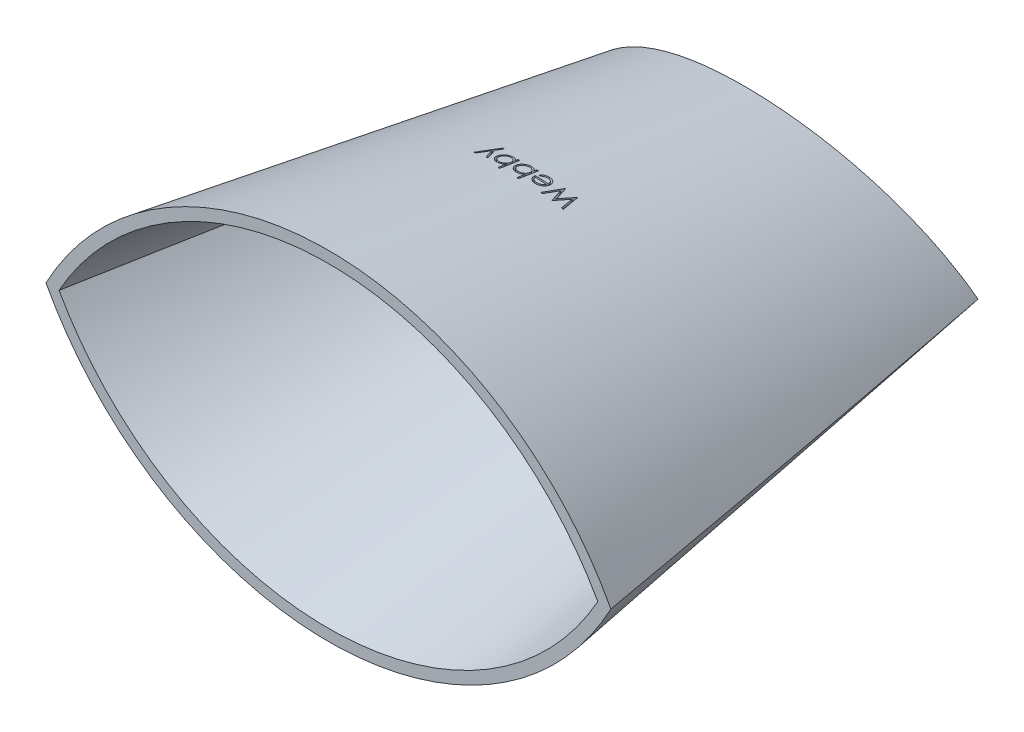
from build123d import *

# Parameters (mm, degrees)
EXTRUDE_2_DEPTH     = 80
EXTRUDE_2_DRAFT     = -9
CUT_EXTRUDE_3_DEPTH = 40
SHELL_4_T           = -2
CUT_EXTRUDE_4_DEPTH = 1


with BuildPart() as part:
    # 草圖13 → 填料-伸長2 (with draft: the straight prism first)
    with BuildSketch(Plane.XY):
        with BuildLine():
            ThreePointArc((-50, 0), (0, -30), (50, 0))
            ThreePointArc((50, 0), (0, 30), (-50, 0))
        make_face()
    extrude(amount=-EXTRUDE_2_DEPTH)
    # 填料-伸長2: the draft: its side faces are tilted about the plane it starts from
    extrude_2_sides = [part.faces().sort_by_distance(p)[0] for p in [
        (0, -30, -40),
        (0, 30, -40),
    ]]
    draft(extrude_2_sides, Plane.XY, EXTRUDE_2_DRAFT)

    # 草圖24 → 除料-伸長3 (cut, symmetric)
    with BuildSketch(Plane(origin=(0, 0, 0), x_dir=(1, 0, 0), z_dir=(0, 1, 0))):
        with BuildLine():
            Line((-34.993272388, 80), (34.993272388, 80))
            ThreePointArc((34.993272388, 80), (0, 73.64656094), (-34.993272388, 80))
        make_face()
    extrude(amount=CUT_EXTRUDE_3_DEPTH, both=True, mode=Mode.SUBTRACT)

    # 薄殼4
    shell_4_openings = [part.faces().sort_by_distance(p)[0] for p in [
        (0, 0, 0),
    ]]
    offset(amount=SHELL_4_T, openings=shell_4_openings)

    # 草圖30 → 除料-伸長4 (cut)
    with BuildSketch(Plane(origin=(0, 29.265847744, -4.635254916), x_dir=(0, -0.156434465, -0.987688341), z_dir=(0, -0.987688341, 0.156434465))):
        Polygon((28.840498656, 8.566973044), (28.840498656, 8.242353653), (31.407305547, 7.55735766), (28.840498656, 6.538627692), (28.840498656, 6.493054775), (31.389777502, 5.493255095), (28.840498656, 4.804753493), (28.840498656, 4.483639711), (32.340498656, 5.427349647), (32.340498656, 5.472221442), (29.663615643, 6.525306377), (32.340498656, 7.591011506), (32.340498656, 7.635883301), align=None)
        with BuildLine():
            Line((31.532806348, 1.666532339), (31.679340803, 1.387485865))
            add(Edge.make_bspline(
                [(31.679340803, 1.387485865), (31.718774784, 1.409734126), (31.795497696, 1.453020431), (31.900911664, 1.527157354), (31.995179199, 1.605585821), (32.076790805, 1.690692099), (32.148863988, 1.779911575), (32.211031138, 1.874938806), (32.264413976, 1.974998142), (32.30815623, 2.081191686), (32.342544509, 2.193392229), (32.367940487, 2.312250839), (32.382667742, 2.438328721), (32.384455188, 2.524666683), (32.385370451, 2.568876089)],
                knots=[0, 0, 0, 0, 0.000135759, 0.000264133, 0.000386042, 0.00050306, 0.000617265, 0.000729664, 0.000843204, 0.000957002, 0.001073654, 0.001194802, 0.001321164, 0.001453767, 0.001453767, 0.001453767, 0.001453767], degree=3))
            add(Edge.make_bspline(
                [(32.385370451, 2.568876089), (32.384223275, 2.618018066), (32.381985468, 2.713879828), (32.362693004, 2.853419576), (32.331220644, 2.984798991), (32.287255108, 3.108010708), (32.229827763, 3.222752908), (32.15986836, 3.329253959), (32.077735806, 3.428072743), (31.982720501, 3.516099768), (31.881034318, 3.595333204), (31.775093709, 3.665296784), (31.665265558, 3.723516513), (31.55220332, 3.771598492), (31.436163915, 3.809526063), (31.316482774, 3.836477979), (31.193634466, 3.851871128), (31.110538858, 3.854240542), (31.06866372, 3.855434583)],
                knots=[0, 0, 0, 0, 0.000147371, 0.000287478, 0.000421649, 0.000552053, 0.000679042, 0.000805636, 0.000933558, 0.00106351, 0.001193382, 0.001319977, 0.001443869, 0.00156576, 0.001688149, 0.001809597, 0.001933259, 0.002058885, 0.002058885, 0.002058885, 0.002058885], degree=3))
            add(Edge.make_bspline(
                [(31.06866372, 3.855434583), (31.029368889, 3.854375441), (30.951491725, 3.852276363), (30.83622618, 3.839045576), (30.724197728, 3.815597283), (30.61531328, 3.783420959), (30.509755146, 3.741869712), (30.407459082, 3.691037493), (30.308533942, 3.630845115), (30.246130808, 3.584372442), (30.214697374, 3.560963429)],
                knots=[0, 0, 0, 0, 0.000117891, 0.000233644, 0.000347498, 0.000460856, 0.000573868, 0.000687374, 0.000803169, 0.000920699, 0.000920699, 0.000920699, 0.000920699], degree=3))
            add(Edge.make_bspline(
                [(30.214697374, 3.560963429), (30.176765715, 3.52931041), (30.102225818, 3.467108733), (30.005175994, 3.360811972), (29.922158166, 3.247262192), (29.854432058, 3.125317218), (29.802339973, 2.995182459), (29.765287562, 2.857529141), (29.742231859, 2.711976793), (29.739388767, 2.612199066), (29.737934553, 2.561163749)],
                knots=[0, 0, 0, 0, 0.000148071, 0.000290976, 0.000430515, 0.000569233, 0.000708282, 0.00084996, 0.000996123, 0.001149162, 0.001149162, 0.001149162, 0.001149162], degree=3))
            add(Edge.make_bspline(
                [(29.737934553, 2.561163749), (29.73928182, 2.508713128), (29.741924852, 2.405816966), (29.766647003, 2.255827455), (29.805375739, 2.113625549), (29.861801668, 1.980384767), (29.931745462, 1.854052066), (30.020151142, 1.737534978), (30.122478089, 1.627635033), (30.201253895, 1.563733148), (30.241340002, 1.531215833)],
                knots=[0, 0, 0, 0, 0.000157241, 0.00030847, 0.000454763, 0.000598385, 0.000741531, 0.000886803, 0.001036096, 0.001190777, 0.001190777, 0.001190777, 0.001190777], degree=3))
            add(Edge.make_bspline(
                [(30.241340002, 1.531215833), (30.271543583, 1.509088894), (30.331749702, 1.464982301), (30.429920859, 1.409735201), (30.532631453, 1.361777806), (30.64154175, 1.323444845), (30.755361331, 1.292405344), (30.874903875, 1.269948525), (31.000133787, 1.256778907), (31.085460342, 1.254190209), (31.128960194, 1.25287048)],
                knots=[0, 0, 0, 0, 0.000112234, 0.000223721, 0.000337279, 0.000451932, 0.000569628, 0.000690912, 0.000816421, 0.00094695, 0.00094695, 0.00094695, 0.00094695], degree=3))
            Line((31.128960194, 1.25287048), (31.128960194, 3.541332019))
            add(Edge.make_bspline(
                [(31.128960194, 3.541332019), (31.162660658, 3.539792412), (31.228931262, 3.536764838), (31.325902045, 3.522649695), (31.418275387, 3.500400921), (31.505358429, 3.469131859), (31.588288557, 3.431265013), (31.666450594, 3.384879297), (31.739488524, 3.329539743), (31.808055661, 3.267814043), (31.869116423, 3.199106948), (31.923768199, 3.126824201), (31.969573796, 3.049930636), (32.006753685, 2.969032552), (32.035860001, 2.884260767), (32.055727822, 2.795588572), (32.069034929, 2.703190456), (32.070514594, 2.640204721), (32.071267886, 2.60813891)],
                knots=[0, 0, 0, 0, 0.000101159, 0.000198924, 0.000293472, 0.000385722, 0.000476069, 0.000566611, 0.000657757, 0.000750573, 0.000842919, 0.000933083, 0.001022062, 0.001110842, 0.001199752, 0.001290403, 0.001383113, 0.001479259, 0.001479259, 0.001479259, 0.001479259], degree=3))
            add(Edge.make_bspline(
                [(32.071267886, 2.60813891), (32.070664726, 2.576786394), (32.069467941, 2.514576989), (32.057663901, 2.421956282), (32.038955523, 2.330675462), (32.012009768, 2.241640922), (31.980456653, 2.156150229), (31.943318839, 2.076543811), (31.900977529, 2.003874104), (31.852861933, 1.935689769), (31.79381146, 1.869912362), (31.720830236, 1.803627852), (31.633090507, 1.734122128), (31.56749233, 1.689910091), (31.532806348, 1.666532339)],
                knots=[0, 0, 0, 0, 9.4016e-05, 0.000186545, 0.000279636, 0.000373251, 0.000465322, 0.000552831, 0.000636406, 0.000717339, 0.000802755, 0.000900997, 0.001012795, 0.001138241, 0.001138241, 0.001138241, 0.001138241], degree=3))
        make_face()
        with BuildLine():
            add(Edge.make_bspline(
                [(30.81485763, 1.566973044), (30.773173936, 1.578423112), (30.693154786, 1.600403523), (30.582386326, 1.647214628), (30.48337455, 1.698662677), (30.397764813, 1.760596005), (30.321610185, 1.830082823), (30.256123611, 1.911453566), (30.195765892, 2.001179093), (30.14550228, 2.101046555), (30.10419769, 2.207117676), (30.073826048, 2.317212277), (30.055972687, 2.430408214), (30.053355141, 2.506648421), (30.052037117, 2.545037948)],
                knots=[0, 0, 0, 0, 0.000129543, 0.00024868, 0.000360034, 0.000463544, 0.000564759, 0.000668354, 0.000776083, 0.000888652, 0.001002969, 0.001117099, 0.00123064, 0.001345797, 0.001345797, 0.001345797, 0.001345797], degree=3))
            add(Edge.make_bspline(
                [(30.052037117, 2.545037948), (30.052641656, 2.576389782), (30.053836702, 2.638365767), (30.065409887, 2.729632223), (30.084006711, 2.817507555), (30.111350477, 2.901729461), (30.144622436, 2.982856615), (30.185520406, 3.060830396), (30.234966768, 3.134648436), (30.272738585, 3.180784607), (30.291820771, 3.204092435)],
                knots=[0, 0, 0, 0, 9.4016e-05, 0.000185849, 0.000275511, 0.000363095, 0.000451113, 0.0005383, 0.000626778, 0.000717114, 0.000717114, 0.000717114, 0.000717114], degree=3))
            add(Edge.make_bspline(
                [(30.291820771, 3.204092435), (30.3069135, 3.220788333), (30.337457506, 3.254576762), (30.390111474, 3.29967645), (30.446922023, 3.34317984), (30.510368986, 3.381838941), (30.578612469, 3.418578677), (30.652150428, 3.452058103), (30.731293269, 3.482499147), (30.786469981, 3.499587549), (30.81485763, 3.508379294)],
                knots=[0, 0, 0, 0, 6.7454e-05, 0.00013651, 0.000207604, 0.000281922, 0.000359087, 0.000440033, 0.000524147, 0.00061328, 0.00061328, 0.00061328, 0.00061328], degree=3))
            Line((30.81485763, 3.508379294), (30.81485763, 1.566973044))
        make_face(mode=Mode.SUBTRACT)
        with BuildLine():
            Line((32.340498656, 0.624665352), (28.750755066, 0.624665352))
            Line((28.750755066, 0.624665352), (28.750755066, 0.310562788))
            Line((28.750755066, 0.310562788), (30.246948976, 0.310562788))
            add(Edge.make_bspline(
                [(30.246948976, 0.310562788), (30.206191044, 0.275169369), (30.126670639, 0.206115349), (30.022822989, 0.090338898), (29.934770512, -0.031066672), (29.862184393, -0.159024927), (29.806910786, -0.29371786), (29.766488396, -0.434449969), (29.742101493, -0.58158101), (29.73933542, -0.681900184), (29.737934553, -0.732706443)],
                knots=[0, 0, 0, 0, 0.000161815, 0.000315708, 0.000465351, 0.000611017, 0.000755934, 0.000901068, 0.001049529, 0.001201867, 0.001201867, 0.001201867, 0.001201867], degree=3))
            add(Edge.make_bspline(
                [(29.737934553, -0.732706443), (29.739174781, -0.777872581), (29.741626924, -0.867173733), (29.760261419, -0.99845588), (29.790479221, -1.124769155), (29.8323714, -1.246044803), (29.887954378, -1.361716935), (29.954495685, -1.472775992), (30.033734015, -1.578652977), (30.124332325, -1.677707862), (30.222688948, -1.769001749), (30.327869263, -1.848914259), (30.438344354, -1.916413955), (30.553744416, -1.972245248), (30.674540767, -2.0154163), (30.800614966, -2.045158568), (30.931842985, -2.064052032), (31.021155788, -2.066432278), (31.066560354, -2.06764234)],
                knots=[0, 0, 0, 0, 0.000135464, 0.000267835, 0.000396906, 0.000524625, 0.000651952, 0.000781211, 0.000912462, 0.00104796, 0.001183414, 0.001314526, 0.001443549, 0.001571179, 0.00169847, 0.001827542, 0.001959218, 0.002095382, 0.002095382, 0.002095382, 0.002095382], degree=3))
            add(Edge.make_bspline(
                [(31.066560354, -2.06764234), (31.111260372, -2.0664059), (31.199401767, -2.063967834), (31.329108324, -2.045346526), (31.453947023, -2.014600261), (31.57359528, -1.970639078), (31.688615193, -1.915374139), (31.797695597, -1.846262864), (31.902734573, -1.766451864), (32.000358205, -1.674120716), (32.090591605, -1.574207163), (32.16899747, -1.46729292), (32.23671459, -1.356070998), (32.290370037, -1.238807886), (32.333770959, -1.117239845), (32.36388865, -0.990064458), (32.381461705, -0.85800123), (32.384057272, -0.768282341), (32.385370451, -0.722890738)],
                knots=[0, 0, 0, 0, 0.000134063, 0.000264351, 0.000392226, 0.000519096, 0.000646094, 0.000774294, 0.000905831, 0.001041249, 0.001176798, 0.001309174, 0.001438434, 0.001566731, 0.001695345, 0.001825098, 0.001958069, 0.002094233, 0.002094233, 0.002094233, 0.002094233], degree=3))
            add(Edge.make_bspline(
                [(32.385370451, -0.722890738), (32.383931434, -0.670924642), (32.381109772, -0.56902819), (32.357668298, -0.419989425), (32.317888848, -0.278857107), (32.264068036, -0.144433417), (32.192685503, -0.017270005), (32.101610199, 0.100656804), (31.993620071, 0.212381709), (31.910179178, 0.277205304), (31.867241444, 0.310562788)],
                knots=[0, 0, 0, 0, 0.00015584, 0.000305575, 0.000451192, 0.000594929, 0.00073903, 0.000887111, 0.001040812, 0.001203751, 0.001203751, 0.001203751, 0.001203751], degree=3))
            Line((31.867241444, 0.310562788), (32.340498656, 0.310562788))
            Line((32.340498656, 0.310562788), (32.340498656, 0.624665352))
        make_face()
        with BuildLine():
            add(Edge.make_bspline(
                [(32.071267886, -0.720086251), (32.069634266, -0.766000616), (32.066409759, -0.856628269), (32.041236013, -0.989671879), (31.999352363, -1.116986767), (31.942066908, -1.237927299), (31.870051352, -1.350616068), (31.782881217, -1.451233724), (31.683325313, -1.540975224), (31.57055897, -1.6151975), (31.451205809, -1.677576163), (31.325867393, -1.720657655), (31.197558735, -1.749232544), (31.110416736, -1.752097777), (31.066560354, -1.753539776)],
                knots=[0, 0, 0, 0, 0.000137677, 0.000271753, 0.000404561, 0.000538791, 0.000672205, 0.000804452, 0.00093703, 0.001072956, 0.001208416, 0.001339907, 0.001469577, 0.001600956, 0.001600956, 0.001600956, 0.001600956], degree=3))
            add(Edge.make_bspline(
                [(31.066560354, -1.753539776), (31.022744812, -1.751652032), (30.935288652, -1.747884081), (30.805638984, -1.721509299), (30.68005136, -1.675451509), (30.558873371, -1.614333485), (30.445865571, -1.5384655), (30.344375444, -1.449459536), (30.256815459, -1.347577731), (30.183825388, -1.234754311), (30.124265835, -1.11457412), (30.08342081, -0.988083487), (30.056682622, -0.857925364), (30.053593494, -0.769529871), (30.052037117, -0.724994103)],
                knots=[0, 0, 0, 0, 0.000131426, 0.000262328, 0.000394949, 0.000531659, 0.000668557, 0.000802185, 0.00093542, 0.001070185, 0.001204391, 0.001336533, 0.001467986, 0.001601464, 0.001601464, 0.001601464, 0.001601464], degree=3))
            add(Edge.make_bspline(
                [(30.052037117, -0.724994103), (30.053592624, -0.679526609), (30.056679989, -0.589282859), (30.083467678, -0.456114442), (30.12451581, -0.326051906), (30.183445172, -0.201761519), (30.25556393, -0.08591795), (30.340278008, 0.017732197), (30.437010896, 0.10679559), (30.544975641, 0.180773441), (30.662267988, 0.239115944), (30.787585375, 0.280646886), (30.919956693, 0.305787061), (31.010593857, 0.308951509), (31.056744649, 0.310562788)],
                knots=[0, 0, 0, 0, 0.000136278, 0.000270483, 0.00040596, 0.000544592, 0.000681933, 0.000814436, 0.000944937, 0.00107504, 0.001205791, 0.001336603, 0.001469989, 0.001608366, 0.001608366, 0.001608366, 0.001608366], degree=3))
            add(Edge.make_bspline(
                [(31.056744649, 0.310562788), (31.092082596, 0.30960333), (31.161638859, 0.307714813), (31.263764712, 0.293281409), (31.361504529, 0.270336859), (31.454925052, 0.237952925), (31.543462143, 0.195688147), (31.627460426, 0.144043872), (31.706975299, 0.083343175), (31.781526306, 0.014440973), (31.849212039, -0.061775561), (31.908862365, -0.142835889), (31.959344813, -0.228519335), (31.99974351, -0.318770143), (32.032655442, -0.412892043), (32.054393174, -0.511787485), (32.069367125, -0.6144597), (32.070627628, -0.684506688), (32.071267886, -0.720086251)],
                knots=[0, 0, 0, 0, 0.000105983, 0.000208608, 0.000308773, 0.00040678, 0.000504626, 0.000602507, 0.000702069, 0.000804274, 0.000906575, 0.001007403, 0.001105765, 0.001204292, 0.001303624, 0.001404312, 0.001507632, 0.001614286, 0.001614286, 0.001614286, 0.001614286], degree=3))
        make_face(mode=Mode.SUBTRACT)
        with BuildLine():
            Line((32.340498656, -2.695847469), (28.750755066, -2.695847469))
            Line((28.750755066, -2.695847469), (28.750755066, -3.009950033))
            Line((28.750755066, -3.009950033), (30.246948976, -3.009950033))
            add(Edge.make_bspline(
                [(30.246948976, -3.009950033), (30.206191044, -3.045343452), (30.126670639, -3.114397471), (30.022822989, -3.230173922), (29.934770512, -3.351579492), (29.862184393, -3.479537748), (29.806910786, -3.614230681), (29.766488396, -3.75496279), (29.742101493, -3.90209383), (29.73933542, -4.002413004), (29.737934553, -4.053219264)],
                knots=[0, 0, 0, 0, 0.000161815, 0.000315708, 0.000465351, 0.000611017, 0.000755934, 0.000901068, 0.001049529, 0.001201867, 0.001201867, 0.001201867, 0.001201867], degree=3))
            add(Edge.make_bspline(
                [(29.737934553, -4.053219264), (29.739174781, -4.098385401), (29.741626924, -4.187686553), (29.760261419, -4.3189687), (29.790479221, -4.445281976), (29.8323714, -4.566557623), (29.887954378, -4.682229756), (29.954495685, -4.793288813), (30.033734015, -4.899165797), (30.124332325, -4.998220683), (30.222688948, -5.089514569), (30.327869263, -5.169427079), (30.438344354, -5.236926775), (30.553744416, -5.292758068), (30.674540767, -5.335929121), (30.800614966, -5.365671388), (30.931842985, -5.384564852), (31.021155788, -5.386945099), (31.066560354, -5.388155161)],
                knots=[0, 0, 0, 0, 0.000135464, 0.000267835, 0.000396906, 0.000524625, 0.000651952, 0.000781211, 0.000912462, 0.00104796, 0.001183414, 0.001314526, 0.001443549, 0.001571179, 0.00169847, 0.001827542, 0.001959218, 0.002095382, 0.002095382, 0.002095382, 0.002095382], degree=3))
            add(Edge.make_bspline(
                [(31.066560354, -5.388155161), (31.111260372, -5.38691872), (31.199401767, -5.384480654), (31.329108324, -5.365859346), (31.453947023, -5.335113082), (31.57359528, -5.291151898), (31.688615193, -5.23588696), (31.797695597, -5.166775684), (31.902734573, -5.086964685), (32.000358205, -4.994633536), (32.090591605, -4.894719983), (32.16899747, -4.78780574), (32.23671459, -4.676583819), (32.290370037, -4.559320706), (32.333770959, -4.437752665), (32.36388865, -4.310577278), (32.381461705, -4.17851405), (32.384057272, -4.088795162), (32.385370451, -4.043403558)],
                knots=[0, 0, 0, 0, 0.000134063, 0.000264351, 0.000392226, 0.000519096, 0.000646094, 0.000774294, 0.000905831, 0.001041249, 0.001176798, 0.001309174, 0.001438434, 0.001566731, 0.001695345, 0.001825098, 0.001958069, 0.002094233, 0.002094233, 0.002094233, 0.002094233], degree=3))
            add(Edge.make_bspline(
                [(32.385370451, -4.043403558), (32.383931434, -3.991437463), (32.381109772, -3.88954101), (32.357668298, -3.740502245), (32.317888848, -3.599369928), (32.264068036, -3.464946238), (32.192685503, -3.337782825), (32.101610199, -3.219856016), (31.993620071, -3.108131112), (31.910179178, -3.043307517), (31.867241444, -3.009950033)],
                knots=[0, 0, 0, 0, 0.00015584, 0.000305575, 0.000451192, 0.000594929, 0.00073903, 0.000887111, 0.001040812, 0.001203751, 0.001203751, 0.001203751, 0.001203751], degree=3))
            Line((31.867241444, -3.009950033), (32.340498656, -3.009950033))
            Line((32.340498656, -3.009950033), (32.340498656, -2.695847469))
        make_face()
        with BuildLine():
            add(Edge.make_bspline(
                [(32.071267886, -4.040599071), (32.069634266, -4.086513436), (32.066409759, -4.17714109), (32.041236013, -4.3101847), (31.999352363, -4.437499587), (31.942066908, -4.558440119), (31.870051352, -4.671128888), (31.782881217, -4.771746545), (31.683325313, -4.861488044), (31.57055897, -4.935710321), (31.451205809, -4.998088984), (31.325867393, -5.041170475), (31.197558735, -5.069745365), (31.110416736, -5.072610597), (31.066560354, -5.074052597)],
                knots=[0, 0, 0, 0, 0.000137677, 0.000271753, 0.000404561, 0.000538791, 0.000672205, 0.000804452, 0.00093703, 0.001072956, 0.001208416, 0.001339907, 0.001469577, 0.001600956, 0.001600956, 0.001600956, 0.001600956], degree=3))
            add(Edge.make_bspline(
                [(31.066560354, -5.074052597), (31.022744812, -5.072164853), (30.935288652, -5.068396902), (30.805638984, -5.042022119), (30.68005136, -4.995964329), (30.558873371, -4.934846306), (30.445865571, -4.858978321), (30.344375444, -4.769972357), (30.256815459, -4.668090551), (30.183825388, -4.555267132), (30.124265835, -4.435086941), (30.08342081, -4.308596307), (30.056682622, -4.178438184), (30.053593494, -4.090042692), (30.052037117, -4.045506924)],
                knots=[0, 0, 0, 0, 0.000131426, 0.000262328, 0.000394949, 0.000531659, 0.000668557, 0.000802185, 0.00093542, 0.001070185, 0.001204391, 0.001336533, 0.001467986, 0.001601464, 0.001601464, 0.001601464, 0.001601464], degree=3))
            add(Edge.make_bspline(
                [(30.052037117, -4.045506924), (30.053592624, -4.000039429), (30.056679989, -3.909795679), (30.083467678, -3.776627263), (30.12451581, -3.646564727), (30.183445172, -3.52227434), (30.25556393, -3.406430771), (30.340278008, -3.302780623), (30.437010896, -3.21371723), (30.544975641, -3.13973938), (30.662267988, -3.081396876), (30.787585375, -3.039865935), (30.919956693, -3.014725759), (31.010593857, -3.011561312), (31.056744649, -3.009950033)],
                knots=[0, 0, 0, 0, 0.000136278, 0.000270483, 0.00040596, 0.000544592, 0.000681933, 0.000814436, 0.000944937, 0.00107504, 0.001205791, 0.001336603, 0.001469989, 0.001608366, 0.001608366, 0.001608366, 0.001608366], degree=3))
            add(Edge.make_bspline(
                [(31.056744649, -3.009950033), (31.092082596, -3.010909491), (31.161638859, -3.012798008), (31.263764712, -3.027231412), (31.361504529, -3.050175962), (31.454925052, -3.082559896), (31.543462143, -3.124824673), (31.627460426, -3.176468949), (31.706975299, -3.237169646), (31.781526306, -3.306071848), (31.849212039, -3.382288382), (31.908862365, -3.463348709), (31.959344813, -3.549032156), (31.99974351, -3.639282964), (32.032655442, -3.733404863), (32.054393174, -3.832300305), (32.069367125, -3.93497252), (32.070627628, -4.005019508), (32.071267886, -4.040599071)],
                knots=[0, 0, 0, 0, 0.000105983, 0.000208608, 0.000308773, 0.00040678, 0.000504626, 0.000602507, 0.000702069, 0.000804274, 0.000906575, 0.001007403, 0.001105765, 0.001204292, 0.001303624, 0.001404312, 0.001507632, 0.001614286, 0.001614286, 0.001614286, 0.001614286], degree=3))
        make_face(mode=Mode.SUBTRACT)
        Polygon((29.782806348, -5.74712952), (29.782806348, -6.085771347), (31.741740643, -6.951656764), (29.782806348, -7.830863494), (29.782806348, -8.170206443), (33.282806348, -6.599693623), (33.282806348, -6.260350674), (32.122449777, -6.781284167), align=None)
    extrude(amount=CUT_EXTRUDE_4_DEPTH, mode=Mode.SUBTRACT)


solid = part.part
